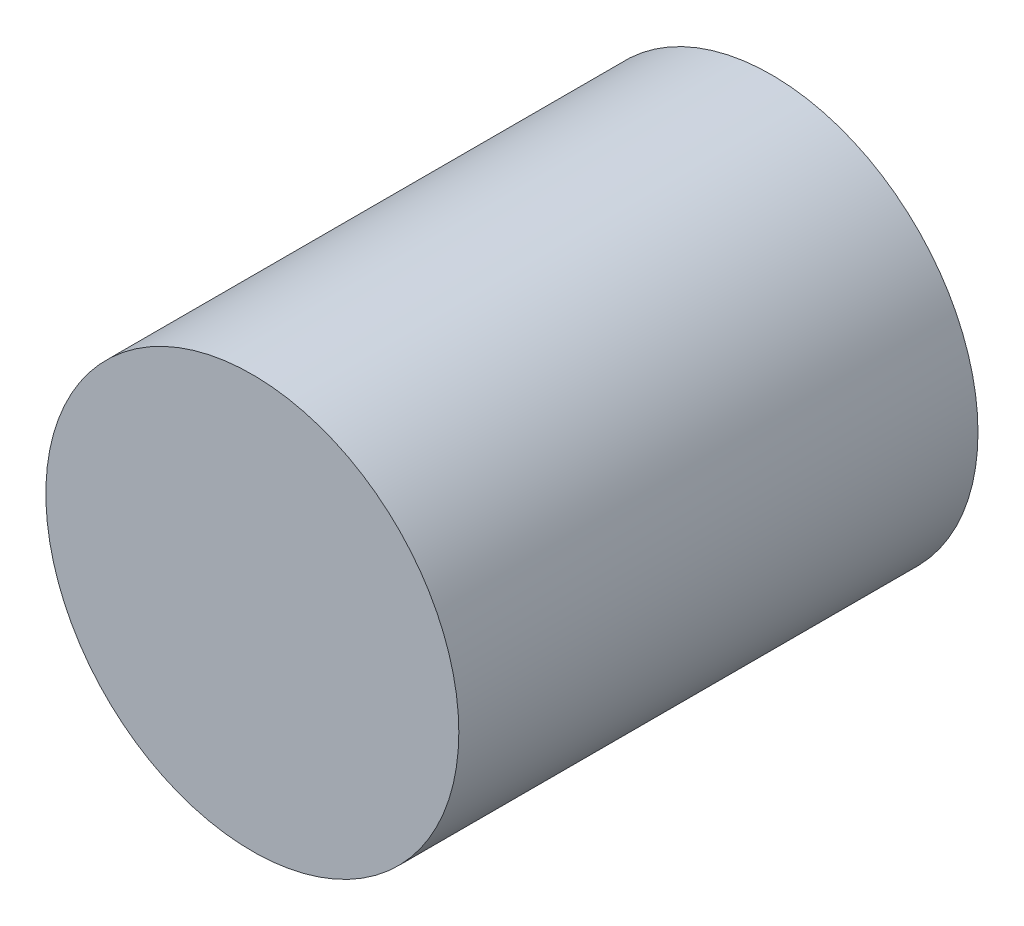
from build123d import *

# Parameters (mm, degrees)
SKETCH1_R           = 17.5
BOSS_EXTRUDE1_DEPTH = 44


with BuildPart() as part:
    # Sketch1 → Boss-Extrude1 (new body)
    with BuildSketch(Plane.XY):
        Circle(SKETCH1_R)
    extrude(amount=BOSS_EXTRUDE1_DEPTH)


solid = part.part
